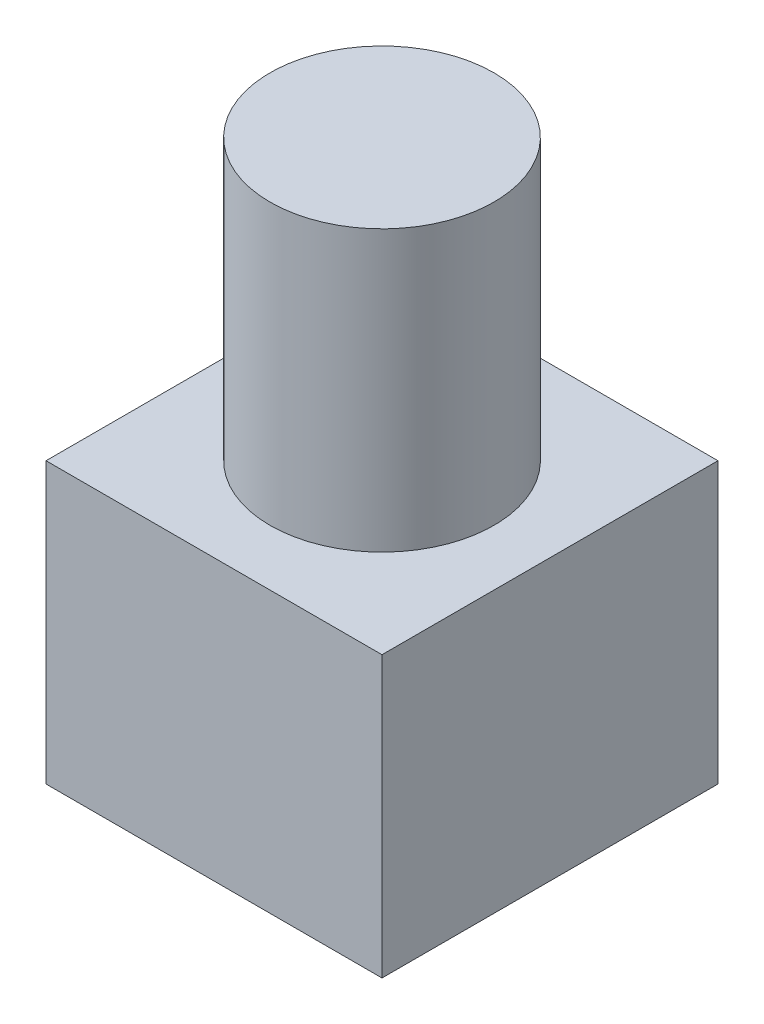
from build123d import *

# Parameters (mm, degrees)
SKETCH1_W           = 6
SKETCH1_H           = 6
BOSS_EXTRUDE1_DEPTH = 5
SKETCH2_R           = 2
BOSS_EXTRUDE2_DEPTH = 5


with BuildPart() as part:
    # Sketch1 → Boss-Extrude1 (new body)
    with BuildSketch(Plane(origin=(0, 0, 0), x_dir=(1, 0, 0), z_dir=(0, 1, 0))):
        with Locations((3, 3)):
            Rectangle(SKETCH1_W, SKETCH1_H)
    extrude(amount=BOSS_EXTRUDE1_DEPTH)

    # Sketch2 → Boss-Extrude2 (add)
    with BuildSketch(Plane(origin=(0, 5, 0), x_dir=(1, 0, 0), z_dir=(0, 1, 0))):
        with Locations((3, 3)):
            Circle(SKETCH2_R)
    extrude(amount=BOSS_EXTRUDE2_DEPTH)


solid = part.part
